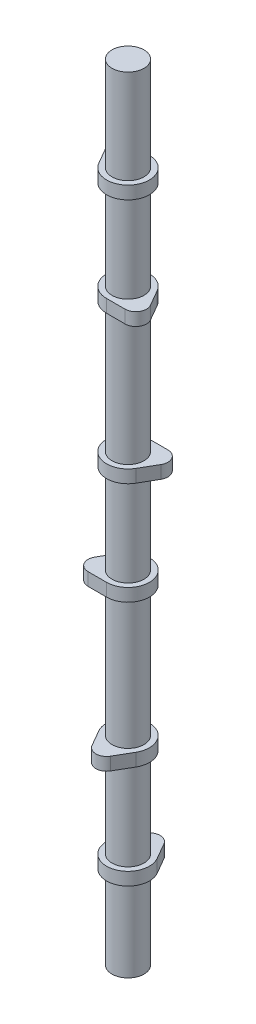
from build123d import *

# Parameters (mm, degrees)
SALIENTE_EXTRUIR1_DEPTH    = 3.81
S_LIDO_MOVER_COPIAR2_ANGLE = 180
SALIENTE_EXTRUIR2_START    = -25.4
CROQUIS2_R                 = 9.5
SALIENTE_EXTRUIR2_DEPTH    = 146.05
MATRIZL1_COUNT             = 3
MATRIZL1_PITCH             = 146.05
S_LIDO_MOVER_COPIAR3_ANGLE = 120
S_LIDO_MOVER_COPIAR4_ANGLE = 120
CROQUIS3_R                 = 9.5
SALIENTE_EXTRUIR3_DEPTH    = 27.94


with BuildPart() as part:
    # Croquis1 → Saliente-Extruir1 (new body, symmetric)
    with BuildSketch(Plane(origin=(0, 0, 0), x_dir=(1, 0, 0), z_dir=(0, 1, 0))):
        with BuildLine():
            Line((-5.499261314, 15.875), (-10.998522628, 6.35))
            ThreePointArc((-10.998522628, 6.35), (0, -12.7), (10.998522628, 6.35))
            Line((10.998522628, 6.35), (5.499261314, 15.875))
            ThreePointArc((5.499261314, 15.875), (0, 19.05), (-5.499261314, 15.875))
        make_face()
    extrude(amount=SALIENTE_EXTRUIR1_DEPTH, both=True)


with BuildPart() as body_2:
    # S_lido-Mover_Copiar1: copy of part
    add(part.part.moved(Location((0, 60.96, 0))))


with BuildPart() as body_2_1:
    # S_lido-Mover_Copiar2: moved
    add(body_2.part.rotate(Axis((0, 0, 0), (0, 1, 0)), S_LIDO_MOVER_COPIAR2_ANGLE))


with BuildPart() as part_1:
    add(part.part)

    add(body_2_1.part)  # Saliente-Extruir2 merges body 2
    # Croquis2 → Saliente-Extruir2 (add)
    with BuildSketch(Plane(origin=(0, 0, 0), x_dir=(1, 0, 0), z_dir=(0, 1, 0)).offset(SALIENTE_EXTRUIR2_START)):
        Circle(CROQUIS2_R)
    extrude(amount=SALIENTE_EXTRUIR2_DEPTH)


with BuildPart() as matrizl1_1:
    # MatrizL1: pattern copy
    add(part_1.part.moved(Location(Vector(0, 1, 0) * (1 * MATRIZL1_PITCH))))


with BuildPart() as matrizl1_2:
    # MatrizL1: pattern copy
    add(part_1.part.moved(Location(Vector(0, 1, 0) * (2 * MATRIZL1_PITCH))))


with BuildPart() as matrizl1_1_1:
    # S_lido-Mover_Copiar3: moved
    add(matrizl1_1.part.rotate(Axis((0, 0, 0), (0, 1, 0)), S_LIDO_MOVER_COPIAR3_ANGLE))


with BuildPart() as matrizl1_2_1:
    # S_lido-Mover_Copiar4: moved
    add(matrizl1_2.part.rotate(Axis((0, 0, 0), (0, -1, 0)), S_LIDO_MOVER_COPIAR4_ANGLE))


with BuildPart() as part_2:
    add(part_1.part)

    # Croquis3 → Saliente-Extruir3 (add)
    with BuildSketch(Plane.XZ.offset(25.4)):
        Circle(CROQUIS3_R)
    extrude(amount=SALIENTE_EXTRUIR3_DEPTH)


with BuildPart() as matrizl1_2_2:
    add(matrizl1_2_1.part)

    # Combinar1: union MatrizL1_1, part
    add(matrizl1_1_1.part)
    add(part_2.part)


solid = matrizl1_2_2.part
